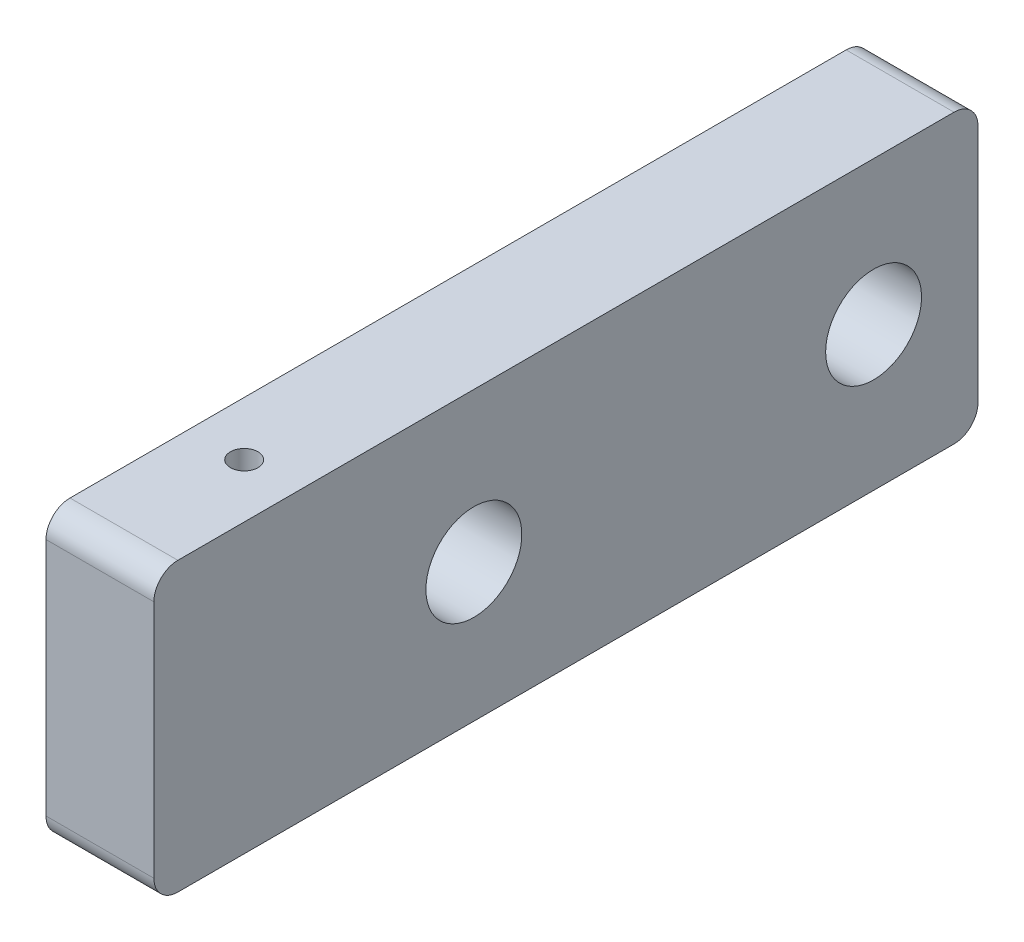
from build123d import *

# Parameters (mm, degrees)
SKETCH1_W           = 68.747968374
SKETCH1_H           = 23.971240905
BOSS_EXTRUDE1_DEPTH = 9
SKETCH2_R           = 4
CUT_EXTRUDE1_DEPTH  = 9
FILLET1_R           = 2
SKETCH3_R           = 1.15
CUT_EXTRUDE2_DEPTH  = 5
CUT_EXTRUDE3_REACH  = 11
SKETCH4_R           = 4


with BuildPart() as part:
    # Sketch1 → Boss-Extrude1 (new body)
    with BuildSketch(Plane.ZY.offset(-74.969208633)):
        with Locations((20.319218255, 7.785620453)):
            Rectangle(SKETCH1_W, SKETCH1_H)
    extrude(amount=BOSS_EXTRUDE1_DEPTH)

    # Sketch2 → Cut-Extrude1 (cut)
    with BuildSketch(Plane.ZY.offset(-65.969208633)):
        with Locations((28, 7.3)):
            Circle(SKETCH2_R)
    extrude(amount=-CUT_EXTRUDE1_DEPTH, mode=Mode.SUBTRACT)

    # Fillet1
    fillet1_edges = [part.edges().sort_by_distance(p)[0] for p in [
        (70.469208633, 19.771240905, -14.054765932),
        (70.469208633, 19.771240905, 54.693202442),
        (70.469208633, -4.2, 54.693202442),
        (70.469208633, -4.2, -14.054765932),
    ]]
    fillet(fillet1_edges, radius=FILLET1_R)

    # Sketch3 → Cut-Extrude2 (cut)
    with BuildSketch(Plane(origin=(0, 19.771240905, 0), x_dir=(1, 0, 0), z_dir=(0, 1, 0))):
        with Locations((70.469208633, -42.659277992)):
            Circle(SKETCH3_R)
    extrude(amount=-CUT_EXTRUDE2_DEPTH, mode=Mode.SUBTRACT)

    # Sketch4 → Cut-Extrude3 (cut, up to next)
    with BuildSketch(Plane.ZY.offset(-65.969208633), mode=Mode.PRIVATE) as cut_extrude3_sk1:
        with Locations((-5.344766421, 7.785620452)):
            Circle(SKETCH4_R)
    cut_extrude3_tool1 = extrude(cut_extrude3_sk1.sketch, amount=-CUT_EXTRUDE3_REACH, mode=Mode.PRIVATE) & part.part
    add(cut_extrude3_tool1.solids().sort_by_distance((65.969209, 7.78562, -5.344766))[0], mode=Mode.SUBTRACT)


solid = part.part
